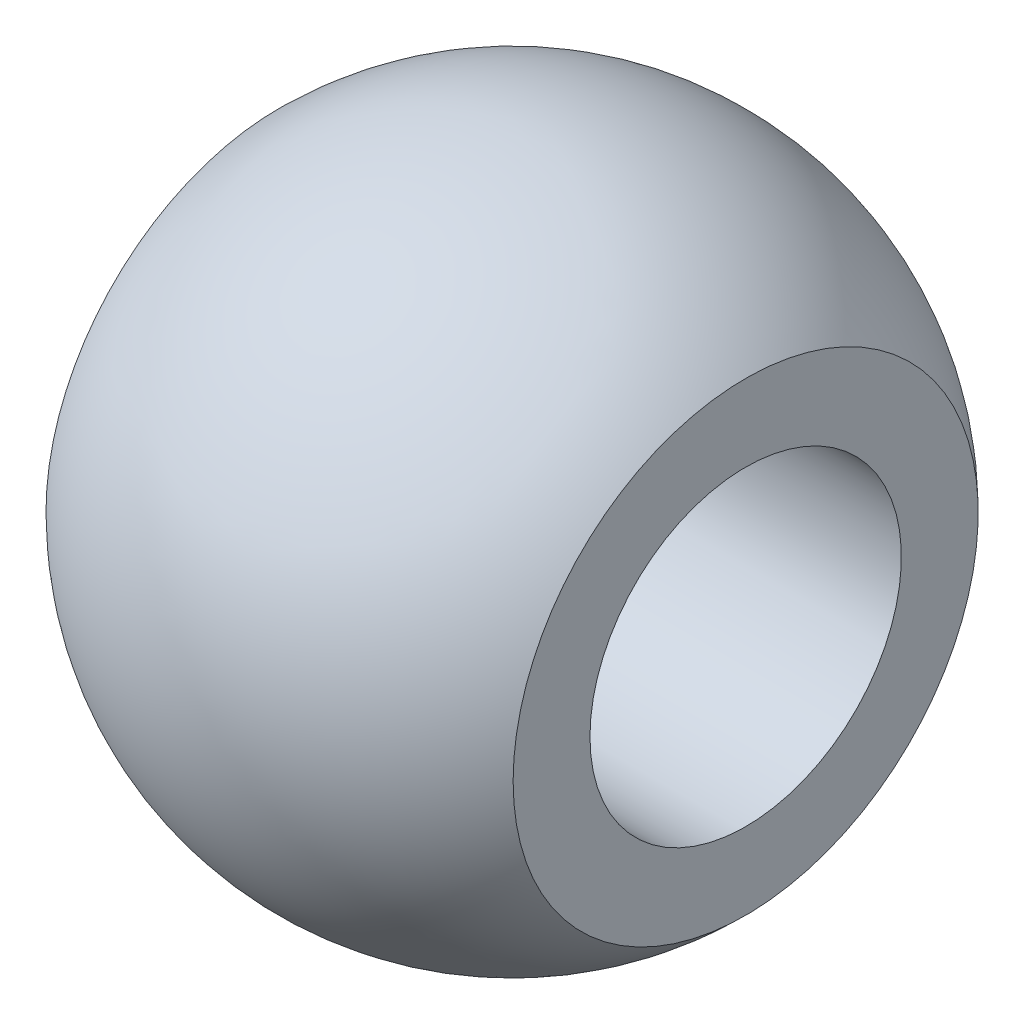
from build123d import *


with BuildPart() as part:
    # 草图1 → 旋转1 (revolve)
    with BuildSketch(Plane.XY):
        with BuildLine():
            Line((-4.5, 3), (4.5, 3))
            Line((4.5, 3), (4.5, 4.480234369))
            ThreePointArc((4.5, 4.480234369), (0, 6.35), (-4.5, 4.480234369))
            Line((-4.5, 4.480234369), (-4.5, 3))
        make_face()
    revolve(axis=Axis((-13.719819454, 0, 0), (1, 0, 0)))


solid = part.part
